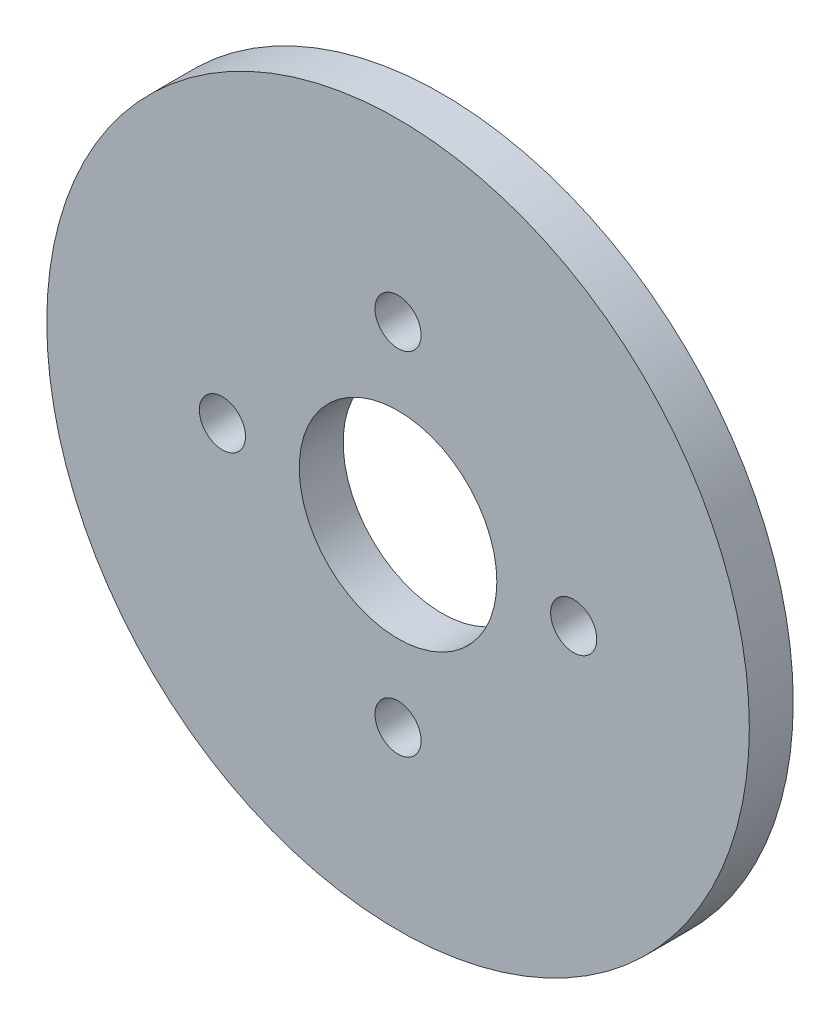
from build123d import *

# Parameters (mm, degrees)
SKETCH1_R           = 16
SKETCH1_R_2         = 4.5
SKETCH1_R_3         = 1.05
BOSS_EXTRUDE1_DEPTH = 2


with BuildPart() as part:
    # Sketch1 → Boss-Extrude1 (new body)
    with BuildSketch(Plane.XY):
        Circle(SKETCH1_R)
        Circle(SKETCH1_R_2, mode=Mode.SUBTRACT)
        with Locations((0, 8)):
            Circle(SKETCH1_R_3, mode=Mode.SUBTRACT)
        with Locations((8, 0)):
            Circle(SKETCH1_R_3, mode=Mode.SUBTRACT)
        with Locations((0, -8)):
            Circle(SKETCH1_R_3, mode=Mode.SUBTRACT)
        with Locations((-8, 0)):
            Circle(SKETCH1_R_3, mode=Mode.SUBTRACT)
    extrude(amount=BOSS_EXTRUDE1_DEPTH)


solid = part.part
